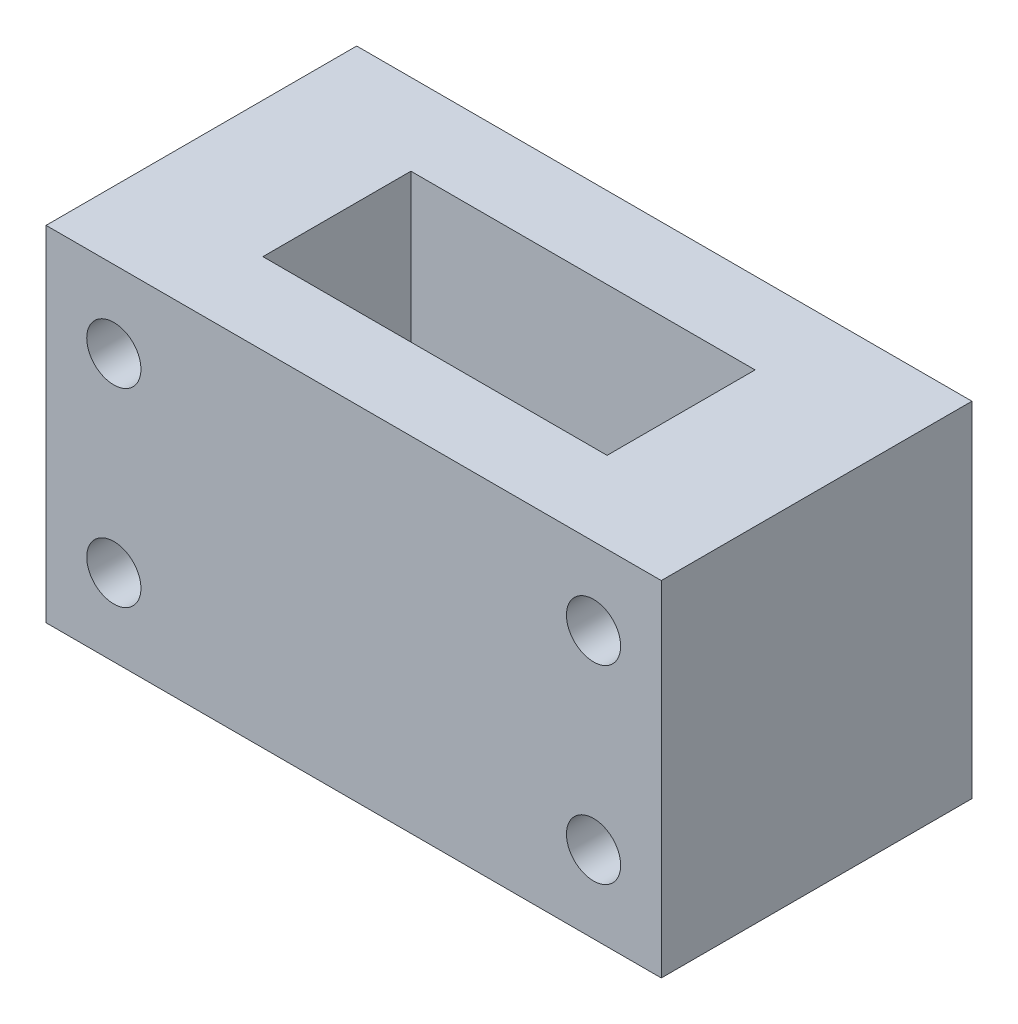
from build123d import *

# Parameters (mm, degrees)
SKETCH1_W           = 45.4
SKETCH1_H           = 22.922
SKETCH1_W_2         = 25.4
SKETCH1_H_2         = 10.922
BOSS_EXTRUDE1_DEPTH = 25.4
SKETCH2_R           = 2
CUT_EXTRUDE1_DEPTH  = 23.922


with BuildPart() as part:
    # Sketch1 → Boss-Extrude1 (new body)
    with BuildSketch(Plane(origin=(0, 0, 0), x_dir=(1, 0, 0), z_dir=(0, 1, 0))):
        Rectangle(SKETCH1_W, SKETCH1_H)
        Rectangle(SKETCH1_W_2, SKETCH1_H_2, mode=Mode.SUBTRACT)
    extrude(amount=BOSS_EXTRUDE1_DEPTH)

    # Sketch2 → Cut-Extrude1 (cut, through all)
    with BuildSketch(Plane(origin=(0, 0, -11.461), x_dir=(-1, 0, 0), z_dir=(0, 0, -1))):
        with Locations((-17.7, 5.7)):
            Circle(SKETCH2_R)
        with Locations((-17.7, 19.7)):
            Circle(SKETCH2_R)
        with Locations((17.7, 19.7)):
            Circle(SKETCH2_R)
        with Locations((17.7, 5.7)):
            Circle(SKETCH2_R)
    extrude(amount=-CUT_EXTRUDE1_DEPTH, mode=Mode.SUBTRACT)


solid = part.part
